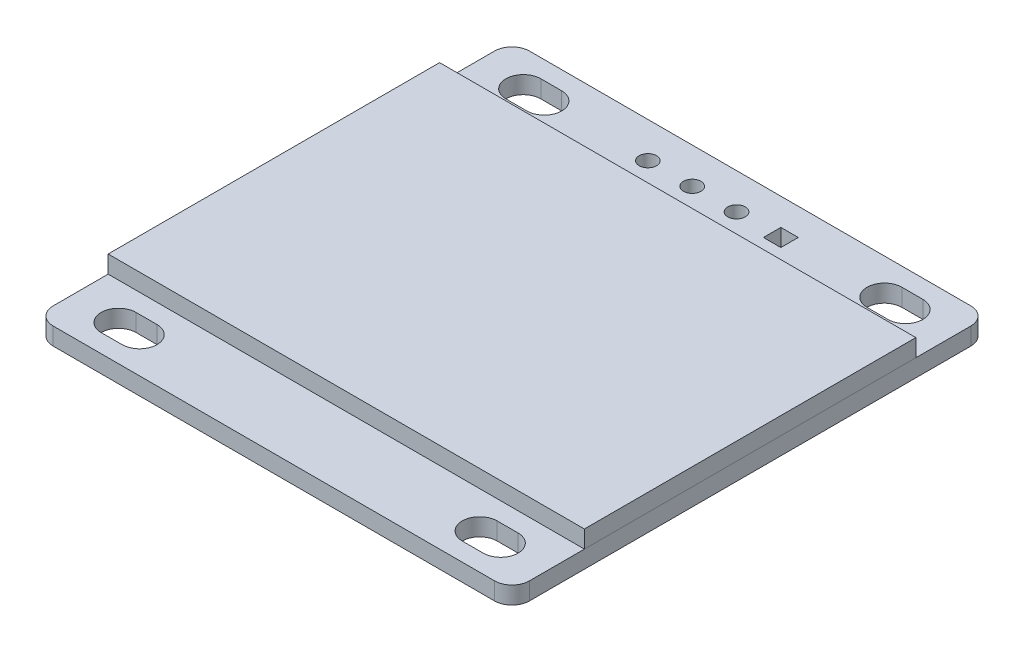
from build123d import *

# Parameters (mm, degrees)
SKICA1_W                 = 27.3
SKICA1_H                 = 27.3
P_IDAT_VYSUNUT_M1_DEPTH  = 1
SKICA2_W                 = 27.3
SKICA2_H                 = 19
P_IDAT_VYSUNUT_M2_DEPTH  = 1
ZAOBLIT1_R               = 1
SKICA3_R                 = 0.5
SKICA3_W                 = 1
SKICA3_H                 = 1
ODEBRAT_VYSUNUT_M1_DEPTH = 1


with BuildPart() as part:
    # Skica1 → Přidat vysunutím1 (new body)
    with BuildSketch(Plane(origin=(0, 0, 0), x_dir=(1, 0, 0), z_dir=(0, 1, 0))):
        with Locations((13.65, 13.65)):
            Rectangle(SKICA1_W, SKICA1_H)
    extrude(amount=P_IDAT_VYSUNUT_M1_DEPTH)

    # Zaoblit1
    zaoblit1_edges = [part.edges().sort_by_distance(p)[0] for p in [
        (0, 0.5, -27.3),
        (27.3, 0.5, -27.3),
        (27.3, 0.5, 0),
        (0, 0.5, 0),
    ]]
    fillet(zaoblit1_edges, radius=ZAOBLIT1_R)

    # Skica3 → Odebrat vysunutím1 (cut)
    with BuildSketch(Plane(origin=(0, 1, 0), x_dir=(1, 0, 0), z_dir=(0, 1, 0))):
        with Locations((9.84, 25.25)):
            Circle(SKICA3_R)
        with Locations((12.38, 25.25)):
            Circle(SKICA3_R)
        with Locations((14.92, 25.25)):
            Circle(SKICA3_R)
        with BuildLine():
            Line((2.7, 26.25), (3.9, 26.25))
            ThreePointArc((3.9, 26.25), (4.9, 25.25), (3.9, 24.25))
            Line((3.9, 24.25), (2.7, 24.25))
            ThreePointArc((2.7, 24.25), (1.7, 25.25), (2.7, 26.25))
        make_face()
        with BuildLine():
            Line((24.6, 26.25), (23.4, 26.25))
            ThreePointArc((23.4, 26.25), (22.4, 25.25), (23.4, 24.25))
            Line((23.4, 24.25), (24.6, 24.25))
            ThreePointArc((24.6, 24.25), (25.6, 25.25), (24.6, 26.25))
        make_face()
        with BuildLine():
            Line((2.7, 1.05), (3.9, 1.05))
            ThreePointArc((3.9, 1.05), (4.9, 2.05), (3.9, 3.05))
            Line((3.9, 3.05), (2.7, 3.05))
            ThreePointArc((2.7, 3.05), (1.7, 2.05), (2.7, 1.05))
        make_face()
        with BuildLine():
            Line((24.6, 1.05), (23.4, 1.05))
            ThreePointArc((23.4, 1.05), (22.4, 2.05), (23.4, 3.05))
            Line((23.4, 3.05), (24.6, 3.05))
            ThreePointArc((24.6, 3.05), (25.6, 2.05), (24.6, 1.05))
        make_face()
        with Locations((17.46, 25.25)):
            Rectangle(SKICA3_W, SKICA3_H)
    extrude(amount=-ODEBRAT_VYSUNUT_M1_DEPTH, mode=Mode.SUBTRACT)


with BuildPart() as body_2:
    # Skica2 → Přidat vysunutím2 (new body)
    with BuildSketch(Plane(origin=(0, 1, 0), x_dir=(1, 0, 0), z_dir=(0, 1, 0))):
        with Locations((13.65, 13.65)):
            Rectangle(SKICA2_W, SKICA2_H)
    extrude(amount=P_IDAT_VYSUNUT_M2_DEPTH)


solid = Compound([part.part, body_2.part])
